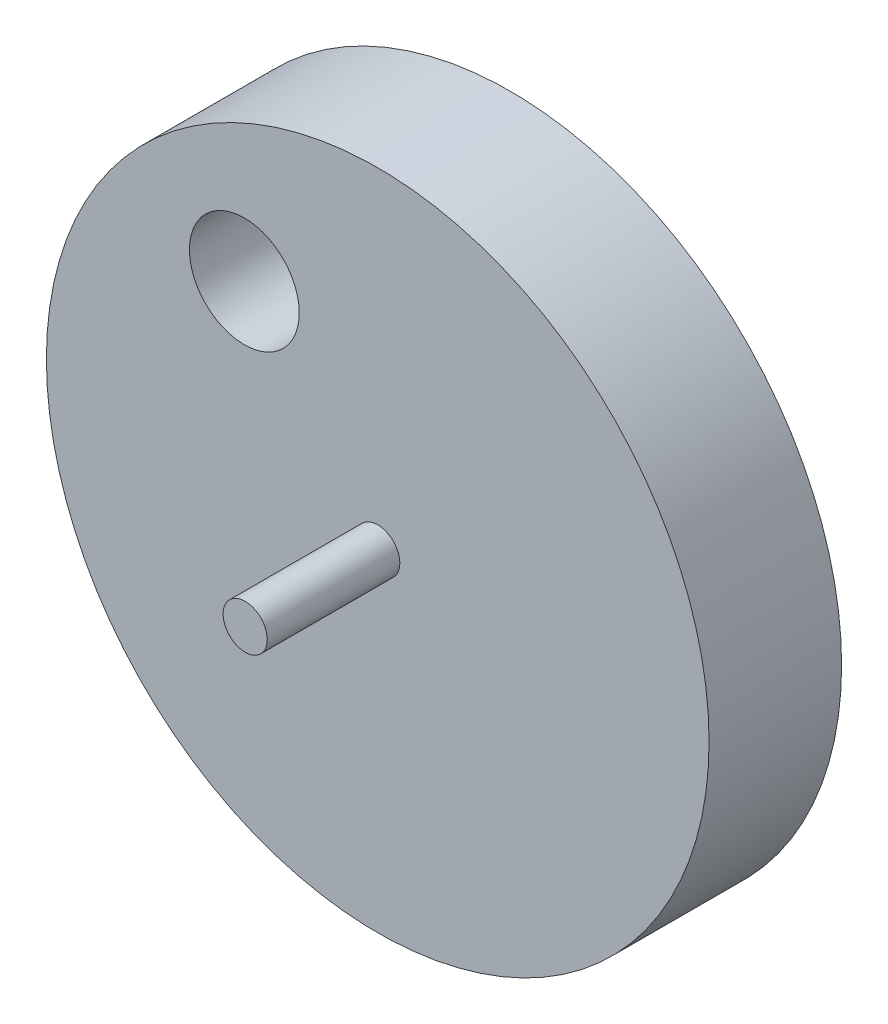
from build123d import *

# Parameters (mm, degrees)
SKETCH_1_R           = 75
SKETCH_1_R_2         = 5
SKETCH_1_R_3         = 12.427488399
EXTRUDE_1_DEPTH      = 30
SKETCH_2_R           = 5
EXTRUDE_2_DEPTH      = 30
EXTRUDE_2_DEPTH_BACK = 60


with BuildPart() as part:
    # 草图1 → 凸台-拉伸1 (new body)
    with BuildSketch(Plane.XY):
        Circle(SKETCH_1_R)
        Circle(SKETCH_1_R_2, mode=Mode.SUBTRACT)
        with Locations((-30.195035009, 37.625475503)):
            Circle(SKETCH_1_R_3, mode=Mode.SUBTRACT)
    extrude(amount=EXTRUDE_1_DEPTH)

    # 草图2 → 凸台-拉伸2 (add, two sides)
    with BuildSketch(Plane.XY.offset(30)) as extrude_2_sk:
        Circle(SKETCH_2_R)
    extrude(amount=EXTRUDE_2_DEPTH)
    extrude(extrude_2_sk.sketch, amount=-EXTRUDE_2_DEPTH_BACK)


solid = part.part
